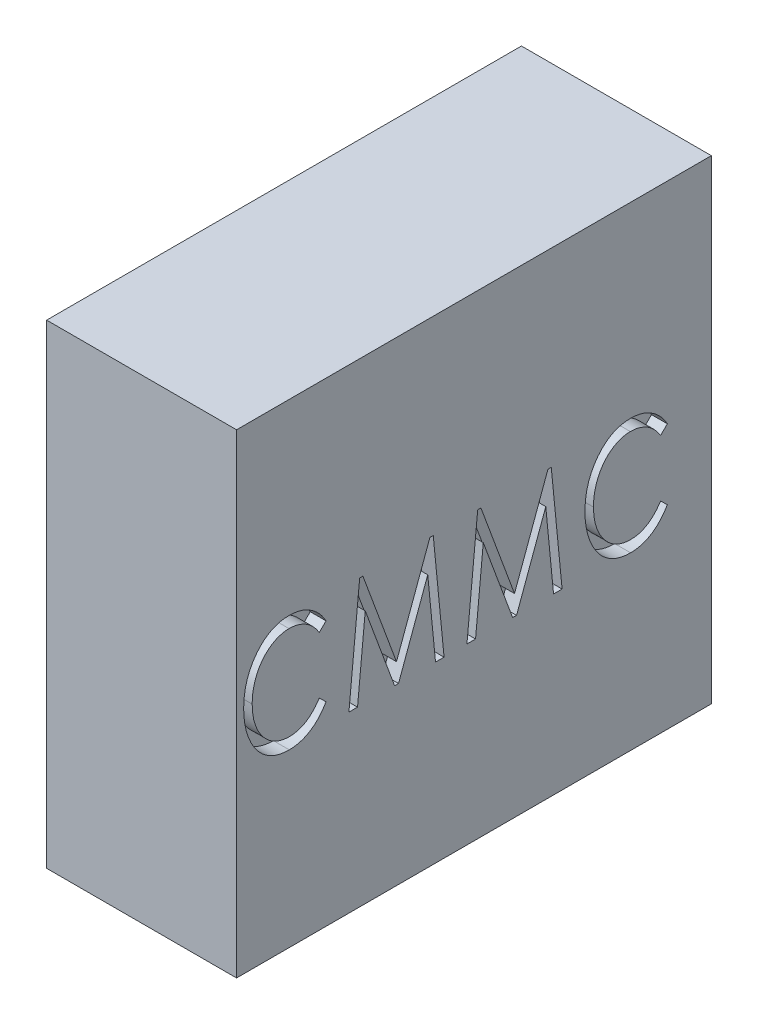
from build123d import *

# Parameters (mm, degrees)
SKETCH1_W             = 15
SKETCH1_H             = 15
SKETCH1_W_2           = 13
SKETCH1_H_2           = 13
BOSS_EXTRUDE1_DEPTH   = 5
BOSS_EXTRUDE1_2_DEPTH = 5
BOSS_EXTRUDE1_3_DEPTH = 5
BOSS_EXTRUDE1_4_DEPTH = 5
BOSS_EXTRUDE1_5_DEPTH = 5
SKETCH2_W             = 15
SKETCH2_H             = 15
BOSS_EXTRUDE2_DEPTH   = 1
CUT_EXTRUDE1_DEPTH    = 0.5
CUT_EXTRUDE2_DEPTH    = 0.5


with BuildPart() as part:
    # Sketch1 → Boss-Extrude1 (new body)
    with BuildSketch(Plane(origin=(0, 0, 0), x_dir=(0, 0, -1), z_dir=(1, 0, 0))):
        Rectangle(SKETCH1_W, SKETCH1_H)
        Rectangle(SKETCH1_W_2, SKETCH1_H_2, mode=Mode.SUBTRACT)
    extrude(amount=BOSS_EXTRUDE1_DEPTH)



with BuildPart() as body_2:
    # Sketch1 → Boss-Extrude1 2 (new body)
    with BuildSketch(Plane(origin=(0, 0, 0), x_dir=(0, 0, -1), z_dir=(1, 0, 0))):
        with BuildLine():
            ThreePointArc((4.392891986, 0.25), (3.111269837, 3.111269837), (0.25, 4.392891986))
            Line((0.25, 4.392891986), (0.25, 3.390796367))
            ThreePointArc((0.25, 3.390796367), (2.404163056, 2.404163056), (3.390796367, 0.25))
            Line((3.390796367, 0.25), (4.392891986, 0.25))
        make_face()
    extrude(amount=BOSS_EXTRUDE1_2_DEPTH)


with BuildPart() as body_3:
    # Sketch1 → Boss-Extrude1 3 (new body)
    with BuildSketch(Plane(origin=(0, 0, 0), x_dir=(0, 0, -1), z_dir=(1, 0, 0))):
        with BuildLine():
            Line((-0.25, 3.390796367), (-0.25, 4.392891986))
            ThreePointArc((-0.25, 4.392891986), (-3.111269837, 3.111269837), (-4.392891986, 0.25))
            Line((-4.392891986, 0.25), (-3.390796367, 0.25))
            ThreePointArc((-3.390796367, 0.25), (-2.404163056, 2.404163056), (-0.25, 3.390796367))
        make_face()
    extrude(amount=BOSS_EXTRUDE1_3_DEPTH)


with BuildPart() as body_4:
    # Sketch1 → Boss-Extrude1 4 (new body)
    with BuildSketch(Plane(origin=(0, 0, 0), x_dir=(0, 0, -1), z_dir=(1, 0, 0))):
        with BuildLine():
            Line((-3.390796367, -0.25), (-4.392891986, -0.25))
            ThreePointArc((-4.392891986, -0.25), (-3.111269837, -3.111269837), (-0.25, -4.392891986))
            Line((-0.25, -4.392891986), (-0.25, -3.390796367))
            ThreePointArc((-0.25, -3.390796367), (-2.404163056, -2.404163056), (-3.390796367, -0.25))
        make_face()
    extrude(amount=BOSS_EXTRUDE1_4_DEPTH)


with BuildPart() as body_5:
    # Sketch1 → Boss-Extrude1 5 (new body)
    with BuildSketch(Plane(origin=(0, 0, 0), x_dir=(0, 0, -1), z_dir=(1, 0, 0))):
        with BuildLine():
            ThreePointArc((0.25, -4.392891986), (3.111269837, -3.111269837), (4.392891986, -0.25))
            Line((4.392891986, -0.25), (3.390796367, -0.25))
            ThreePointArc((3.390796367, -0.25), (2.404163056, -2.404163056), (0.25, -3.390796367))
            Line((0.25, -3.390796367), (0.25, -4.392891986))
        make_face()
    extrude(amount=BOSS_EXTRUDE1_5_DEPTH)


with BuildPart() as part_1:
    add(part.part)

    add(body_2.part)  # Boss-Extrude2 merges body 2

    add(body_3.part)  # Boss-Extrude2 merges body 3

    add(body_4.part)  # Boss-Extrude2 merges body 4

    add(body_5.part)  # Boss-Extrude2 merges body 5
    # Sketch2 → Boss-Extrude2 (add)
    with BuildSketch(Plane(origin=(5, 0, 0), x_dir=(0, 0, -1), z_dir=(1, 0, 0))):
        Rectangle(SKETCH2_W, SKETCH2_H)
    extrude(amount=BOSS_EXTRUDE2_DEPTH)

    # Sketch3 → Cut-Extrude1 (cut)
    with BuildSketch(Plane.XZ.offset(7.5)):
        with BuildLine():
            Line((3.981186558, 4.673076923), (3.77085002, 4.886217949))
            add(Edge.make_bspline(
                [(3.77085002, 4.886217949), (3.816419611, 4.91586299), (3.905242756, 4.973646389), (4.023635288, 5.074436653), (4.124576166, 5.184094398), (4.207761774, 5.302438407), (4.273565556, 5.428217307), (4.319998869, 5.560938708), (4.349296132, 5.699404782), (4.352542577, 5.794025153), (4.354183353, 5.841846955)],
                knots=[0, 0, 0, 0, 0.000162964, 0.000317645, 0.000465029, 0.000608969, 0.000750398, 0.000889434, 0.001029686, 0.001173005, 0.001173005, 0.001173005, 0.001173005], degree=3))
            add(Edge.make_bspline(
                [(4.354183353, 5.841846955), (4.353775382, 5.868290676), (4.352963739, 5.920899494), (4.3424334, 5.998669172), (4.327114821, 6.075125488), (4.305555036, 6.15004989), (4.276807911, 6.223299924), (4.243763497, 6.295840329), (4.202361947, 6.36580568), (4.156274398, 6.434607721), (4.104737722, 6.500689077), (4.048556711, 6.563289217), (3.987897798, 6.62162497), (3.923244317, 6.676386666), (3.854577054, 6.727706216), (3.781142684, 6.774829784), (3.703602798, 6.818065622), (3.6221328, 6.857416407), (3.537285024, 6.892210042), (3.449994273, 6.923458914), (3.359292971, 6.948175203), (3.26667342, 6.970503925), (3.170979527, 6.986031253), (3.073029673, 6.998297115), (2.972377371, 7.005345301), (2.904273894, 7.006053098), (2.869908513, 7.006410256)],
                knots=[0, 0, 0, 0, 7.9276e-05, 0.000157717, 0.000234994, 0.000313099, 0.000391223, 0.000470895, 0.000551947, 0.000634786, 0.000719215, 0.000803119, 0.000886917, 0.000971482, 0.00105716, 0.001143898, 0.00123304, 0.001323351, 0.001415145, 0.001508056, 0.001601281, 0.00169703, 0.001793737, 0.001891919, 0.001993123, 0.00209621, 0.00209621, 0.00209621, 0.00209621], degree=3))
            add(Edge.make_bspline(
                [(2.869908513, 7.006410256), (2.818209937, 7.005647259), (2.716884595, 7.004151842), (2.568380135, 6.987120775), (2.42643897, 6.961763101), (2.290744424, 6.92519269), (2.161859545, 6.877400881), (2.039025492, 6.819737014), (1.922942439, 6.751628325), (1.814982095, 6.673378765), (1.716154604, 6.587740999), (1.629578775, 6.495361498), (1.55688757, 6.396983797), (1.4962829, 6.293937888), (1.449790406, 6.184534204), (1.417221706, 6.069547768), (1.395697396, 5.949454675), (1.393673496, 5.86741573), (1.392644891, 5.825721154)],
                knots=[0, 0, 0, 0, 0.000155026, 0.000303839, 0.000447821, 0.000587287, 0.000724821, 0.000859684, 0.000993879, 0.001127955, 0.001259141, 0.001385641, 0.001506937, 0.001625385, 0.001743501, 0.00186244, 0.001983352, 0.002108311, 0.002108311, 0.002108311, 0.002108311], degree=3))
            add(Edge.make_bspline(
                [(1.392644891, 5.825721154), (1.39434134, 5.779772219), (1.397695995, 5.688910155), (1.426198427, 5.555773368), (1.471815151, 5.428428025), (1.536958469, 5.307299671), (1.619463603, 5.191691721), (1.721153693, 5.082732604), (1.840189739, 4.978892209), (1.929718375, 4.917789826), (1.975978225, 4.886217949)],
                knots=[0, 0, 0, 0, 0.000137722, 0.000272339, 0.000406517, 0.000542329, 0.000683575, 0.000831433, 0.000988475, 0.001156373, 0.001156373, 0.001156373, 0.001156373], degree=3))
            Line((1.975978225, 4.886217949), (1.767745052, 4.673076923))
            add(Edge.make_bspline(
                [(1.767745052, 4.673076923), (1.739274804, 4.689829157), (1.682809452, 4.723054045), (1.602534679, 4.777649368), (1.527234545, 4.83532573), (1.456747734, 4.895921112), (1.390917257, 4.959348542), (1.330508179, 5.026314974), (1.27474902, 5.095900914), (1.224347513, 5.168736016), (1.179384428, 5.244305239), (1.140813443, 5.322498963), (1.107776082, 5.402605548), (1.08023778, 5.484735667), (1.059123209, 5.569130961), (1.044654311, 5.655892385), (1.035077983, 5.744642927), (1.034141383, 5.804662492), (1.033670533, 5.834835737)],
                knots=[0, 0, 0, 0, 9.9079e-05, 0.000196505, 0.000291021, 0.000383495, 0.000475224, 0.000565069, 0.000653871, 0.000742557, 0.000830575, 0.000917429, 0.001003883, 0.001090352, 0.001177076, 0.001264561, 0.001354069, 0.001444557, 0.001444557, 0.001444557, 0.001444557], degree=3))
            add(Edge.make_bspline(
                [(1.033670533, 5.834835737), (1.033934355, 5.863603576), (1.034456568, 5.920546891), (1.042844684, 6.00452211), (1.054329699, 6.086322688), (1.07159214, 6.165551774), (1.091950533, 6.242957475), (1.119442949, 6.317477436), (1.149744968, 6.390409774), (1.185682453, 6.460682446), (1.226627611, 6.528265924), (1.272280046, 6.593630146), (1.322937882, 6.656589736), (1.377730964, 6.717880716), (1.437310953, 6.776794186), (1.501975029, 6.832956144), (1.57182906, 6.886359811), (1.620822474, 6.919922712), (1.645749859, 6.936999199)],
                knots=[0, 0, 0, 0, 8.6264e-05, 0.000170751, 0.00025295, 0.000333944, 0.000413884, 0.000492834, 0.000572008, 0.000650712, 0.00072935, 0.000808902, 0.000889711, 0.000971634, 0.00105542, 0.0011409, 0.001228405, 0.001319043, 0.001319043, 0.001319043, 0.001319043], degree=3))
            add(Edge.make_bspline(
                [(1.645749859, 6.936999199), (1.689482214, 6.964184192), (1.777268168, 7.018753871), (1.917513045, 7.086836373), (2.063871927, 7.145473628), (2.217032954, 7.192970699), (2.37683181, 7.230181446), (2.543146712, 7.256783157), (2.716304876, 7.272181291), (2.833887103, 7.274473893), (2.893746654, 7.275641026)],
                knots=[0, 0, 0, 0, 0.00015439, 0.000309914, 0.00046693, 0.000627037, 0.000790472, 0.000958761, 0.001131925, 0.0013115, 0.0013115, 0.0013115, 0.0013115], degree=3))
            add(Edge.make_bspline(
                [(2.893746654, 7.275641026), (2.956672574, 7.274562862), (3.080271666, 7.272445134), (3.261567085, 7.251820556), (3.435454871, 7.220984625), (3.601648204, 7.176102211), (3.759830604, 7.117238866), (3.911319939, 7.047703194), (4.054207466, 6.963253449), (4.188664056, 6.868154086), (4.31133314, 6.763365), (4.418910025, 6.650886666), (4.509234466, 6.531335099), (4.584623392, 6.406042512), (4.642449898, 6.273295704), (4.683000638, 6.13403206), (4.708422567, 5.988373055), (4.711561173, 5.888927218), (4.713157712, 5.838341346)],
                knots=[0, 0, 0, 0, 0.000188707, 0.000370659, 0.000546687, 0.000718128, 0.000886271, 0.00105252, 0.0012175, 0.001383442, 0.001546031, 0.001700762, 0.001849401, 0.001994654, 0.002138457, 0.00228244, 0.002428941, 0.002580617, 0.002580617, 0.002580617, 0.002580617], degree=3))
            add(Edge.make_bspline(
                [(4.713157712, 5.838341346), (4.712678701, 5.807702824), (4.711729461, 5.746987442), (4.702322085, 5.657002414), (4.68695764, 5.569402822), (4.665555711, 5.484004434), (4.639537463, 5.400404531), (4.605219086, 5.319705772), (4.565979665, 5.240966728), (4.521096922, 5.164538699), (4.470873387, 5.091090376), (4.414922592, 5.021395873), (4.354745075, 4.95491083), (4.289799119, 4.891297819), (4.220037669, 4.831303411), (4.144948921, 4.774869722), (4.065402956, 4.721638478), (4.009422047, 4.689358304), (3.981186558, 4.673076923)],
                knots=[0, 0, 0, 0, 9.189e-05, 0.000182095, 0.000271082, 0.000358487, 0.000446071, 0.000533441, 0.000621236, 0.000709858, 0.000799121, 0.000887923, 0.000977767, 0.001068003, 0.001160476, 0.001253586, 0.001349647, 0.001447405, 0.001447405, 0.001447405, 0.001447405], degree=3))
        make_face()
        Polygon((1.123414122, 4.179487179), (4.623414122, 3.839443109), (4.623414122, 3.737780449), (1.75161925, 2.676282051), (4.623414122, 1.62109375), (4.623414122, 1.515224359), (1.123414122, 1.173076923), (1.123414122, 1.443008814), (3.636234635, 1.689102564), (1.123414122, 2.611778846), (1.123414122, 2.735176282), (3.636234635, 3.663461538), (1.123414122, 3.907451923), align=None)
        Polygon((1.123414122, 0.679487179), (4.623414122, 0.339443109), (4.623414122, 0.237780449), (1.75161925, -0.823717949), (4.623414122, -1.87890625), (4.623414122, -1.984775641), (1.123414122, -2.326923077), (1.123414122, -2.056991186), (3.636234635, -1.810897436), (1.123414122, -0.888221154), (1.123414122, -0.764823718), (3.636234635, 0.163461538), (1.123414122, 0.407451923), align=None)
        with BuildLine():
            Line((3.981186558, -5.423076923), (3.77085002, -5.209935897))
            add(Edge.make_bspline(
                [(3.77085002, -5.209935897), (3.816419611, -5.180290856), (3.905242756, -5.122507457), (4.023635288, -5.021717193), (4.124576166, -4.912059448), (4.207761774, -4.79371544), (4.273565556, -4.667936539), (4.319998869, -4.535215138), (4.349296132, -4.396749065), (4.352542577, -4.302128693), (4.354183353, -4.254306891)],
                knots=[0, 0, 0, 0, 0.000162964, 0.000317645, 0.000465029, 0.000608969, 0.000750398, 0.000889434, 0.001029686, 0.001173005, 0.001173005, 0.001173005, 0.001173005], degree=3))
            add(Edge.make_bspline(
                [(4.354183353, -4.254306891), (4.353775382, -4.22786317), (4.352963739, -4.175254353), (4.3424334, -4.097484674), (4.327114821, -4.021028358), (4.305555036, -3.946103956), (4.276807911, -3.872853922), (4.243763497, -3.800313517), (4.202361947, -3.730348166), (4.156274398, -3.661546125), (4.104737722, -3.59546477), (4.048556711, -3.532864629), (3.987897798, -3.474528876), (3.923244317, -3.419767181), (3.854577054, -3.36844763), (3.781142684, -3.321324062), (3.703602798, -3.278088224), (3.6221328, -3.238737439), (3.537285024, -3.203943804), (3.449994273, -3.172694932), (3.359292971, -3.147978643), (3.26667342, -3.125649921), (3.170979527, -3.110122593), (3.073029673, -3.097856731), (2.972377371, -3.090808545), (2.904273894, -3.090100748), (2.869908513, -3.08974359)],
                knots=[0, 0, 0, 0, 7.9276e-05, 0.000157717, 0.000234994, 0.000313099, 0.000391223, 0.000470895, 0.000551947, 0.000634786, 0.000719215, 0.000803119, 0.000886917, 0.000971482, 0.00105716, 0.001143898, 0.00123304, 0.001323351, 0.001415145, 0.001508056, 0.001601281, 0.00169703, 0.001793737, 0.001891919, 0.001993123, 0.00209621, 0.00209621, 0.00209621, 0.00209621], degree=3))
            add(Edge.make_bspline(
                [(2.869908513, -3.08974359), (2.818209937, -3.090506587), (2.716884595, -3.092002004), (2.568380135, -3.109033072), (2.42643897, -3.134390745), (2.290744424, -3.170961156), (2.161859545, -3.218752965), (2.039025492, -3.276416833), (1.922942439, -3.344525521), (1.814982095, -3.422775081), (1.716154604, -3.508412847), (1.629578775, -3.600792348), (1.55688757, -3.699170049), (1.4962829, -3.802215958), (1.449790406, -3.911619643), (1.417221706, -4.026606078), (1.395697396, -4.146699171), (1.393673496, -4.228738116), (1.392644891, -4.270432692)],
                knots=[0, 0, 0, 0, 0.000155026, 0.000303839, 0.000447821, 0.000587287, 0.000724821, 0.000859684, 0.000993879, 0.001127955, 0.001259141, 0.001385641, 0.001506937, 0.001625385, 0.001743501, 0.00186244, 0.001983352, 0.002108311, 0.002108311, 0.002108311, 0.002108311], degree=3))
            add(Edge.make_bspline(
                [(1.392644891, -4.270432692), (1.39434134, -4.316381627), (1.397695995, -4.407243691), (1.426198427, -4.540380478), (1.471815151, -4.667725821), (1.536958469, -4.788854175), (1.619463603, -4.904462125), (1.721153693, -5.013421242), (1.840189739, -5.117261637), (1.929718375, -5.17836402), (1.975978225, -5.209935897)],
                knots=[0, 0, 0, 0, 0.000137722, 0.000272339, 0.000406517, 0.000542329, 0.000683575, 0.000831433, 0.000988475, 0.001156373, 0.001156373, 0.001156373, 0.001156373], degree=3))
            Line((1.975978225, -5.209935897), (1.767745052, -5.423076923))
            add(Edge.make_bspline(
                [(1.767745052, -5.423076923), (1.739274804, -5.406324689), (1.682809452, -5.373099802), (1.602534679, -5.318504479), (1.527234545, -5.260828116), (1.456747734, -5.200232734), (1.390917257, -5.136805304), (1.330508179, -5.069838872), (1.27474902, -5.000252932), (1.224347513, -4.927417831), (1.179384428, -4.851848607), (1.140813443, -4.773654884), (1.107776082, -4.693548298), (1.08023778, -4.611418179), (1.059123209, -4.527022885), (1.044654311, -4.440261462), (1.035077983, -4.351510919), (1.034141383, -4.291491354), (1.033670533, -4.261318109)],
                knots=[0, 0, 0, 0, 9.9079e-05, 0.000196505, 0.000291021, 0.000383495, 0.000475224, 0.000565069, 0.000653871, 0.000742557, 0.000830575, 0.000917429, 0.001003883, 0.001090352, 0.001177076, 0.001264561, 0.001354069, 0.001444557, 0.001444557, 0.001444557, 0.001444557], degree=3))
            add(Edge.make_bspline(
                [(1.033670533, -4.261318109), (1.033934355, -4.23255027), (1.034456568, -4.175606955), (1.042844684, -4.091631737), (1.054329699, -4.009831159), (1.07159214, -3.930602072), (1.091950533, -3.853196371), (1.119442949, -3.778676411), (1.149744968, -3.705744072), (1.185682453, -3.6354714), (1.226627611, -3.567887923), (1.272280046, -3.5025237), (1.322937882, -3.43956411), (1.377730964, -3.378273131), (1.437310953, -3.319359661), (1.501975029, -3.263197702), (1.57182906, -3.209794035), (1.620822474, -3.176231134), (1.645749859, -3.159154647)],
                knots=[0, 0, 0, 0, 8.6264e-05, 0.000170751, 0.00025295, 0.000333944, 0.000413884, 0.000492834, 0.000572008, 0.000650712, 0.00072935, 0.000808902, 0.000889711, 0.000971634, 0.00105542, 0.0011409, 0.001228405, 0.001319043, 0.001319043, 0.001319043, 0.001319043], degree=3))
            add(Edge.make_bspline(
                [(1.645749859, -3.159154647), (1.689482214, -3.131969654), (1.777268168, -3.077399976), (1.917513045, -3.009317473), (2.063871927, -2.950680218), (2.217032954, -2.903183147), (2.37683181, -2.8659724), (2.543146712, -2.839370689), (2.716304876, -2.823972555), (2.833887103, -2.821679953), (2.893746654, -2.820512821)],
                knots=[0, 0, 0, 0, 0.00015439, 0.000309914, 0.00046693, 0.000627037, 0.000790472, 0.000958761, 0.001131925, 0.0013115, 0.0013115, 0.0013115, 0.0013115], degree=3))
            add(Edge.make_bspline(
                [(2.893746654, -2.820512821), (2.956672574, -2.821590984), (3.080271666, -2.823708713), (3.261567085, -2.84433329), (3.435454871, -2.875169221), (3.601648204, -2.920051635), (3.759830604, -2.97891498), (3.911319939, -3.048450652), (4.054207466, -3.132900397), (4.188664056, -3.22799976), (4.31133314, -3.332788846), (4.418910025, -3.445267181), (4.509234466, -3.564818747), (4.584623392, -3.690111334), (4.642449898, -3.822858142), (4.683000638, -3.962121786), (4.708422567, -4.107780791), (4.711561173, -4.207226628), (4.713157712, -4.2578125)],
                knots=[0, 0, 0, 0, 0.000188707, 0.000370659, 0.000546687, 0.000718128, 0.000886271, 0.00105252, 0.0012175, 0.001383442, 0.001546031, 0.001700762, 0.001849401, 0.001994654, 0.002138457, 0.00228244, 0.002428941, 0.002580617, 0.002580617, 0.002580617, 0.002580617], degree=3))
            add(Edge.make_bspline(
                [(4.713157712, -4.2578125), (4.712678701, -4.288451022), (4.711729461, -4.349166404), (4.702322085, -4.439151432), (4.68695764, -4.526751024), (4.665555711, -4.612149412), (4.639537463, -4.695749315), (4.605219086, -4.776448074), (4.565979665, -4.855187118), (4.521096922, -4.931615147), (4.470873387, -5.00506347), (4.414922592, -5.074757973), (4.354745075, -5.141243016), (4.289799119, -5.204856027), (4.220037669, -5.264850435), (4.144948921, -5.321284124), (4.065402956, -5.374515368), (4.009422047, -5.406795542), (3.981186558, -5.423076923)],
                knots=[0, 0, 0, 0, 9.189e-05, 0.000182095, 0.000271082, 0.000358487, 0.000446071, 0.000533441, 0.000621236, 0.000709858, 0.000799121, 0.000887923, 0.000977767, 0.001068003, 0.001160476, 0.001253586, 0.001349647, 0.001447405, 0.001447405, 0.001447405, 0.001447405], degree=3))
        make_face()
    extrude(amount=-CUT_EXTRUDE1_DEPTH, mode=Mode.SUBTRACT)

    # Sketch4 → Cut-Extrude2 (cut)
    with BuildSketch(Plane(origin=(6, 0, 0), x_dir=(0, 0, -1), z_dir=(1, 0, 0))):
        with BuildLine():
            Line((-4.673076923, 0.857772436), (-4.886217949, 0.647435897))
            add(Edge.make_bspline(
                [(-4.886217949, 0.647435897), (-4.915873395, 0.692994375), (-4.973677075, 0.78179586), (-5.074435461, 0.900474094), (-5.184756829, 1.000961509), (-5.302990773, 1.084161665), (-5.428363796, 1.15032285), (-5.560952001, 1.196557235), (-5.699401361, 1.225889089), (-5.794024005, 1.229130831), (-5.841846955, 1.230769231)],
                knots=[0, 0, 0, 0, 0.000162964, 0.000317645, 0.000465547, 0.000609487, 0.000750294, 0.00088933, 0.001029582, 0.001172901, 0.001172901, 0.001172901, 0.001172901], degree=3))
            add(Edge.make_bspline(
                [(-5.841846955, 1.230769231), (-5.868292427, 1.230368401), (-5.920904727, 1.229570966), (-5.998875952, 1.218904353), (-6.075429992, 1.203960196), (-6.15039753, 1.181799073), (-6.223705081, 1.15379366), (-6.29609306, 1.119927812), (-6.3663945, 1.079174868), (-6.435220487, 1.033037513), (-6.500783845, 0.981134039), (-6.563259488, 0.924898761), (-6.622391561, 0.864962699), (-6.676292864, 0.799550577), (-6.727756632, 0.731206415), (-6.774815445, 0.657716419), (-6.818070906, 0.580192305), (-6.857409848, 0.498716571), (-6.892231351, 0.413875719), (-6.923379252, 0.326562785), (-6.94846268, 0.235994761), (-6.969327472, 0.143069818), (-6.986346352, 0.047664023), (-6.998208369, -0.050400845), (-7.005368254, -0.151032511), (-7.006060796, -0.219138806), (-7.006410256, -0.253505609)],
                knots=[0, 0, 0, 0, 7.9276e-05, 0.000157717, 0.000235681, 0.000313113, 0.000391892, 0.000470929, 0.000552588, 0.000635427, 0.000719304, 0.000803208, 0.000887494, 0.000971608, 0.001057286, 0.001144024, 0.001233166, 0.001323477, 0.00141527, 0.001508182, 0.001601407, 0.001696999, 0.001793825, 0.001892007, 0.001993212, 0.002096298, 0.002096298, 0.002096298, 0.002096298], degree=3))
            add(Edge.make_bspline(
                [(-7.006410256, -0.253505609), (-7.005655026, -0.305206461), (-7.004174831, -0.406536262), (-6.987034281, -0.555008651), (-6.962061323, -0.69712641), (-6.924070371, -0.832385786), (-6.877651206, -0.961726305), (-6.819661641, -1.084362307), (-6.751648881, -1.200479458), (-6.673371883, -1.308427263), (-6.587748139, -1.407270521), (-6.495340734, -1.493798094), (-6.396893255, -1.56677834), (-6.293505433, -1.626740432), (-6.184388246, -1.673815413), (-6.06953109, -1.706156132), (-5.949459038, -1.727726216), (-5.8674172, -1.729743824), (-5.825721154, -1.730769231)],
                knots=[0, 0, 0, 0, 0.000155026, 0.000303839, 0.000447821, 0.000587471, 0.000724764, 0.000859628, 0.000993823, 0.001127898, 0.001259085, 0.001385584, 0.00150688, 0.001625935, 0.001743406, 0.001862345, 0.001983257, 0.002108216, 0.002108216, 0.002108216, 0.002108216], degree=3))
            add(Edge.make_bspline(
                [(-5.825721154, -1.730769231), (-5.779774098, -1.729069472), (-5.68891575, -1.72570827), (-5.555751606, -1.697254039), (-5.428315046, -1.651384756), (-5.306793485, -1.586891419), (-5.191654625, -1.503669498), (-5.082702924, -1.402304318), (-4.978900429, -1.283212228), (-4.917792626, -1.193691606), (-4.886217949, -1.147435897)],
                knots=[0, 0, 0, 0, 0.000137722, 0.000272339, 0.000406517, 0.000542948, 0.000683624, 0.000831483, 0.000988524, 0.001156422, 0.001156422, 0.001156422, 0.001156422], degree=3))
            Line((-4.886217949, -1.147435897), (-4.673076923, -1.355669071))
            add(Edge.make_bspline(
                [(-4.673076923, -1.355669071), (-4.689829206, -1.384139256), (-4.723054191, -1.440604484), (-4.777648801, -1.520880162), (-4.835327767, -1.596176994), (-4.895913708, -1.666675777), (-4.959375711, -1.732462413), (-5.026352089, -1.793154017), (-5.096556121, -1.848426112), (-5.169396862, -1.899127542), (-5.244882889, -1.943814095), (-5.322637923, -1.982789018), (-5.402620193, -2.015608929), (-5.484731731, -2.043184165), (-5.569132026, -2.064288797), (-5.655892092, -2.078760392), (-5.744643002, -2.088335991), (-5.804662517, -2.089272689), (-5.834835737, -2.08974359)],
                knots=[0, 0, 0, 0, 9.9079e-05, 0.000196505, 0.000291021, 0.000383495, 0.000475224, 0.000565069, 0.00065442, 0.000743106, 0.000831124, 0.00091735, 0.001003805, 0.001090273, 0.001176997, 0.001264483, 0.001353991, 0.001444479, 0.001444479, 0.001444479, 0.001444479], degree=3))
            add(Edge.make_bspline(
                [(-5.834835737, -2.08974359), (-5.863603586, -2.089479786), (-5.92054692, -2.088957609), (-6.004521997, -2.080569226), (-6.086323095, -2.069085191), (-6.165550285, -2.051819176), (-6.242962928, -2.031473863), (-6.317457331, -2.003933296), (-6.390292492, -1.97389003), (-6.4602168, -1.937315916), (-6.528182022, -1.897039387), (-6.593608185, -1.85109638), (-6.656595745, -1.800486556), (-6.717879056, -1.74568031), (-6.776794644, -1.686103957), (-6.832956018, -1.621438876), (-6.886359845, -1.551585119), (-6.919922724, -1.502591667), (-6.936999199, -1.477664263)],
                knots=[0, 0, 0, 0, 8.6264e-05, 0.000170751, 0.00025295, 0.000333944, 0.000413884, 0.000492834, 0.000572008, 0.000650088, 0.000729327, 0.000808879, 0.000889688, 0.000971611, 0.001055397, 0.001140877, 0.001228382, 0.00131902, 0.00131902, 0.00131902, 0.00131902], degree=3))
            add(Edge.make_bspline(
                [(-6.936999199, -1.477664263), (-6.964184192, -1.433931908), (-7.018753871, -1.346145954), (-7.086836373, -1.205901077), (-7.145473628, -1.059542196), (-7.192970699, -0.906381168), (-7.230181446, -0.746582313), (-7.256783157, -0.58026741), (-7.272181291, -0.407109246), (-7.274473893, -0.289527019), (-7.275641026, -0.229667468)],
                knots=[0, 0, 0, 0, 0.00015439, 0.000309914, 0.00046693, 0.000627037, 0.000790472, 0.000958761, 0.001131925, 0.0013115, 0.0013115, 0.0013115, 0.0013115], degree=3))
            add(Edge.make_bspline(
                [(-7.275641026, -0.229667468), (-7.274564949, -0.166740721), (-7.272451318, -0.043140004), (-7.251797169, 0.138143688), (-7.221068319, 0.312073938), (-7.175822105, 0.478036872), (-7.118359269, 0.636793869), (-7.047342666, 0.787481665), (-6.964154987, 0.931036892), (-6.868783147, 1.065208861), (-6.764089133, 1.187937594), (-6.651565114, 1.295462667), (-6.531941319, 1.386051575), (-6.406157354, 1.461010796), (-6.273314344, 1.519067209), (-6.134026996, 1.559577975), (-5.988374383, 1.585010684), (-5.888927666, 1.588147806), (-5.838341346, 1.58974359)],
                knots=[0, 0, 0, 0, 0.000188707, 0.000370659, 0.000546687, 0.000718128, 0.00088603, 0.001052575, 0.001217202, 0.001383144, 0.001545733, 0.001700464, 0.001849103, 0.001994958, 0.002138762, 0.002282745, 0.002429246, 0.002580922, 0.002580922, 0.002580922, 0.002580922], degree=3))
            add(Edge.make_bspline(
                [(-5.838341346, 1.58974359), (-5.80770285, 1.589264529), (-5.746987518, 1.58831519), (-5.657002119, 1.578908545), (-5.569403906, 1.563541385), (-5.484000462, 1.542149403), (-5.400419382, 1.516094121), (-5.319842985, 1.481995444), (-5.241545054, 1.442350347), (-5.165199028, 1.397744275), (-5.091745909, 1.347219971), (-5.021432871, 1.291756618), (-4.954937464, 1.231297177), (-4.891290474, 1.166394311), (-4.831305412, 1.096621009), (-4.774869169, 1.021535501), (-4.721638621, 0.941988652), (-4.689358352, 0.886007864), (-4.673076923, 0.857772436)],
                knots=[0, 0, 0, 0, 9.189e-05, 0.000182095, 0.000271082, 0.000358487, 0.000446071, 0.000533441, 0.000620609, 0.000709231, 0.000798494, 0.000887845, 0.00097769, 0.001067925, 0.001160399, 0.001253508, 0.00134957, 0.001447328, 0.001447328, 0.001447328, 0.001447328], degree=3))
        make_face()
        Polygon((-3.950641026, -2), (-3.610596955, 1.5), (-3.508934295, 1.5), (-2.447435897, -1.371794872), (-1.392247596, 1.5), (-1.286378205, 1.5), (-0.944230769, -2), (-1.21416266, -2), (-1.46025641, 0.512820513), (-2.382932692, -2), (-2.506330128, -2), (-3.434615385, 0.512820513), (-3.678605769, -2), align=None)
        Polygon((-0.221794872, -2), (0.118249199, 1.5), (0.219911859, 1.5), (1.281410256, -1.371794872), (2.336598558, 1.5), (2.442467949, 1.5), (2.784615385, -2), (2.514683494, -2), (2.268589744, 0.512820513), (1.345913462, -2), (1.222516026, -2), (0.294230769, 0.512820513), (0.050240385, -2), align=None)
        with BuildLine():
            Line((6.109615385, 0.857772436), (5.896474359, 0.647435897))
            add(Edge.make_bspline(
                [(5.896474359, 0.647435897), (5.866818912, 0.692994375), (5.809015232, 0.78179586), (5.708256847, 0.900474094), (5.597935478, 1.000961509), (5.479701535, 1.084161665), (5.354328512, 1.15032285), (5.221740307, 1.196557235), (5.083290946, 1.225889089), (4.988668303, 1.229130831), (4.940845353, 1.230769231)],
                knots=[0, 0, 0, 0, 0.000162964, 0.000317645, 0.000465547, 0.000609487, 0.000750294, 0.00088933, 0.001029582, 0.001172901, 0.001172901, 0.001172901, 0.001172901], degree=3))
            add(Edge.make_bspline(
                [(4.940845353, 1.230769231), (4.914399881, 1.230368401), (4.861787581, 1.229570966), (4.783816356, 1.218904353), (4.707262316, 1.203960196), (4.632294777, 1.181799073), (4.558987227, 1.15379366), (4.486599247, 1.119927812), (4.416297808, 1.079174868), (4.347471821, 1.033037513), (4.281908463, 0.981134039), (4.219432819, 0.924898761), (4.160300747, 0.864962699), (4.106399443, 0.799550577), (4.054935675, 0.731206415), (4.007876862, 0.657716419), (3.964621402, 0.580192305), (3.925282459, 0.498716571), (3.890460957, 0.413875719), (3.859313055, 0.326562785), (3.834229628, 0.235994761), (3.813364835, 0.143069818), (3.796345956, 0.047664023), (3.784483939, -0.050400845), (3.777324053, -0.151032511), (3.776631512, -0.219138806), (3.776282051, -0.253505609)],
                knots=[0, 0, 0, 0, 7.9276e-05, 0.000157717, 0.000235681, 0.000313113, 0.000391892, 0.000470929, 0.000552588, 0.000635427, 0.000719304, 0.000803208, 0.000887494, 0.000971608, 0.001057286, 0.001144024, 0.001233166, 0.001323477, 0.00141527, 0.001508182, 0.001601407, 0.001696999, 0.001793825, 0.001892007, 0.001993212, 0.002096298, 0.002096298, 0.002096298, 0.002096298], degree=3))
            add(Edge.make_bspline(
                [(3.776282051, -0.253505609), (3.777037282, -0.305206461), (3.778517477, -0.406536262), (3.795658026, -0.555008651), (3.820630984, -0.69712641), (3.858621937, -0.832385786), (3.905041101, -0.961726305), (3.963030667, -1.084362307), (4.031043427, -1.200479458), (4.109320425, -1.308427263), (4.194944168, -1.407270521), (4.287351573, -1.493798094), (4.385799053, -1.56677834), (4.489186875, -1.626740432), (4.598304062, -1.673815413), (4.713161218, -1.706156132), (4.83323327, -1.727726216), (4.915275107, -1.729743824), (4.956971154, -1.730769231)],
                knots=[0, 0, 0, 0, 0.000155026, 0.000303839, 0.000447821, 0.000587471, 0.000724764, 0.000859628, 0.000993823, 0.001127898, 0.001259085, 0.001385584, 0.00150688, 0.001625935, 0.001743406, 0.001862345, 0.001983257, 0.002108216, 0.002108216, 0.002108216, 0.002108216], degree=3))
            add(Edge.make_bspline(
                [(4.956971154, -1.730769231), (5.00291821, -1.729069472), (5.093776558, -1.72570827), (5.226940702, -1.697254039), (5.354377262, -1.651384756), (5.475898823, -1.586891419), (5.591037682, -1.503669498), (5.699989383, -1.402304318), (5.803791879, -1.283212228), (5.864899682, -1.193691606), (5.896474359, -1.147435897)],
                knots=[0, 0, 0, 0, 0.000137722, 0.000272339, 0.000406517, 0.000542948, 0.000683624, 0.000831483, 0.000988524, 0.001156422, 0.001156422, 0.001156422, 0.001156422], degree=3))
            Line((5.896474359, -1.147435897), (6.109615385, -1.355669071))
            add(Edge.make_bspline(
                [(6.109615385, -1.355669071), (6.092863102, -1.384139256), (6.059638117, -1.440604484), (6.005043507, -1.520880162), (5.94736454, -1.596176994), (5.8867786, -1.666675777), (5.823316596, -1.732462413), (5.756340219, -1.793154017), (5.686136187, -1.848426112), (5.613295446, -1.899127542), (5.537809418, -1.943814095), (5.460054384, -1.982789018), (5.380072115, -2.015608929), (5.297960576, -2.043184165), (5.213560281, -2.064288797), (5.126800215, -2.078760392), (5.038049306, -2.088335991), (4.978029791, -2.089272689), (4.947856571, -2.08974359)],
                knots=[0, 0, 0, 0, 9.9079e-05, 0.000196505, 0.000291021, 0.000383495, 0.000475224, 0.000565069, 0.00065442, 0.000743106, 0.000831124, 0.00091735, 0.001003805, 0.001090273, 0.001176997, 0.001264483, 0.001353991, 0.001444479, 0.001444479, 0.001444479, 0.001444479], degree=3))
            add(Edge.make_bspline(
                [(4.947856571, -2.08974359), (4.919088721, -2.089479786), (4.862145387, -2.088957609), (4.778170311, -2.080569226), (4.696369213, -2.069085191), (4.617142023, -2.051819176), (4.539729379, -2.031473863), (4.465234976, -2.003933296), (4.392399816, -1.97389003), (4.322475507, -1.937315916), (4.254510285, -1.897039387), (4.189084123, -1.85109638), (4.126096562, -1.800486556), (4.064813251, -1.74568031), (4.005897664, -1.686103957), (3.94973629, -1.621438876), (3.896332463, -1.551585119), (3.862769584, -1.502591667), (3.845693109, -1.477664263)],
                knots=[0, 0, 0, 0, 8.6264e-05, 0.000170751, 0.00025295, 0.000333944, 0.000413884, 0.000492834, 0.000572008, 0.000650088, 0.000729327, 0.000808879, 0.000889688, 0.000971611, 0.001055397, 0.001140877, 0.001228382, 0.00131902, 0.00131902, 0.00131902, 0.00131902], degree=3))
            add(Edge.make_bspline(
                [(3.845693109, -1.477664263), (3.818508116, -1.433931908), (3.763938437, -1.346145954), (3.695855935, -1.205901077), (3.63721868, -1.059542196), (3.589721609, -0.906381168), (3.552510861, -0.746582313), (3.52590915, -0.58026741), (3.510511016, -0.407109246), (3.508218415, -0.289527019), (3.507051282, -0.229667468)],
                knots=[0, 0, 0, 0, 0.00015439, 0.000309914, 0.00046693, 0.000627037, 0.000790472, 0.000958761, 0.001131925, 0.0013115, 0.0013115, 0.0013115, 0.0013115], degree=3))
            add(Edge.make_bspline(
                [(3.507051282, -0.229667468), (3.508127359, -0.166740721), (3.51024099, -0.043140004), (3.530895139, 0.138143688), (3.561623989, 0.312073938), (3.606870202, 0.478036872), (3.664333039, 0.636793869), (3.735349642, 0.787481665), (3.81853732, 0.931036892), (3.913909161, 1.065208861), (4.018603175, 1.187937594), (4.131127194, 1.295462667), (4.250750989, 1.386051575), (4.376534954, 1.461010796), (4.509377964, 1.519067209), (4.648665312, 1.559577975), (4.794317925, 1.585010684), (4.893764642, 1.588147806), (4.944350962, 1.58974359)],
                knots=[0, 0, 0, 0, 0.000188707, 0.000370659, 0.000546687, 0.000718128, 0.00088603, 0.001052575, 0.001217202, 0.001383144, 0.001545733, 0.001700464, 0.001849103, 0.001994958, 0.002138762, 0.002282745, 0.002429246, 0.002580922, 0.002580922, 0.002580922, 0.002580922], degree=3))
            add(Edge.make_bspline(
                [(4.944350962, 1.58974359), (4.974989458, 1.589264529), (5.03570479, 1.58831519), (5.125690189, 1.578908545), (5.213288402, 1.563541385), (5.298691846, 1.542149403), (5.382272926, 1.516094121), (5.462849323, 1.481995444), (5.541147254, 1.442350347), (5.61749328, 1.397744275), (5.690946398, 1.347219971), (5.761259437, 1.291756618), (5.827754844, 1.231297177), (5.891401834, 1.166394311), (5.951386896, 1.096621009), (6.007823139, 1.021535501), (6.061053686, 0.941988652), (6.093333955, 0.886007864), (6.109615385, 0.857772436)],
                knots=[0, 0, 0, 0, 9.189e-05, 0.000182095, 0.000271082, 0.000358487, 0.000446071, 0.000533441, 0.000620609, 0.000709231, 0.000798494, 0.000887845, 0.00097769, 0.001067925, 0.001160399, 0.001253508, 0.00134957, 0.001447328, 0.001447328, 0.001447328, 0.001447328], degree=3))
        make_face()
    extrude(amount=-CUT_EXTRUDE2_DEPTH, mode=Mode.SUBTRACT)


solid = part_1.part
